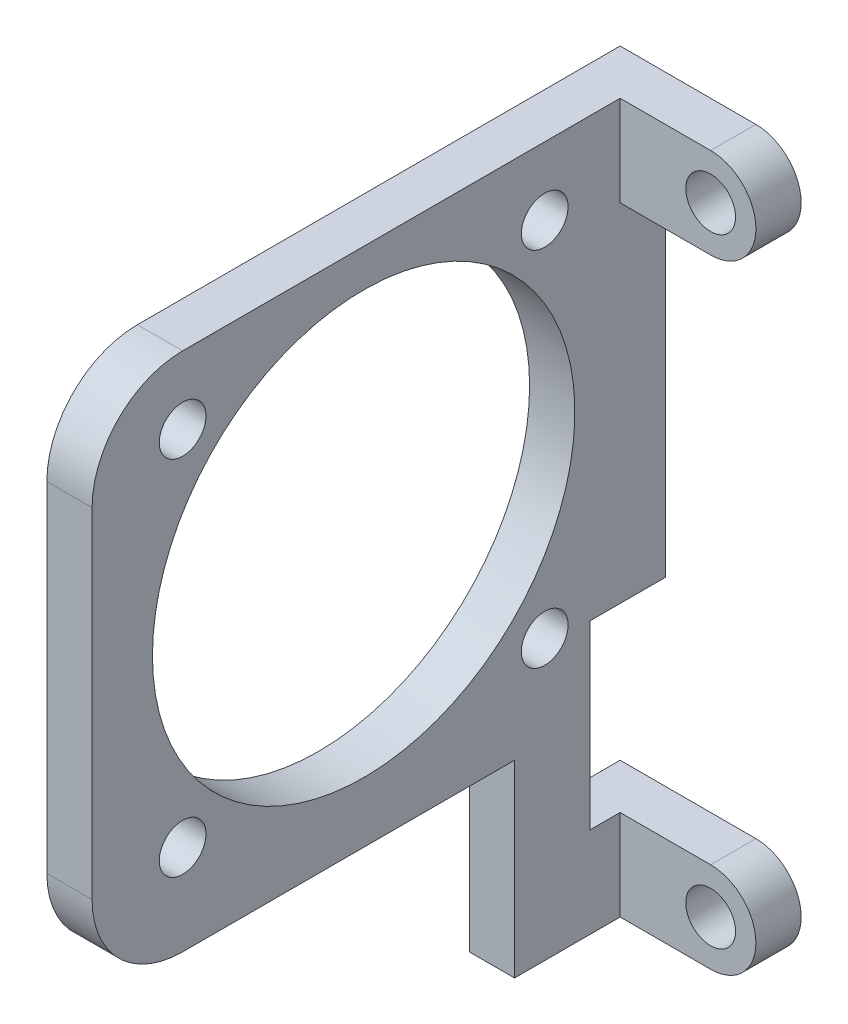
from build123d import *

# Parameters (mm, degrees)
ESBO_O1_R                  = 1.65
RESSALTO_EXTRUS_O1_DEPTH   = 40
ESBO_O2_W                  = 9
ESBO_O2_H                  = 37
CORTE_EXTRUS_O1_DEPTH      = 48
ESBO_O3_R                  = 14
ESBO_O3_R_2                = 1.55
ESBO_O3_W                  = 5
ESBO_O3_H                  = 12
CORTE_EXTRUS_O2_DEPTH      = 1
CORTE_EXTRUS_O2_DEPTH_BACK = 3
FILETE1_R                  = 6


with BuildPart() as part:
    # Esboço1 → Ressalto-extrusão1 (new body)
    with BuildSketch(Plane.XY):
        with BuildLine():
            Line((0, 23.5), (-9, 23.5))
            Line((-9, 23.5), (-9, -23.5))
            Line((-9, -23.5), (0, -23.5))
            ThreePointArc((0, -23.5), (3, -20.5), (0, -17.5))
            Line((0, -17.5), (-6, -17.5))
            Line((-6, -17.5), (-6, 17.5))
            Line((-6, 17.5), (0, 17.5))
            ThreePointArc((0, 17.5), (3, 20.5), (0, 23.5))
        make_face()
        with Locations((0, 20.5)):
            Circle(ESBO_O1_R, mode=Mode.SUBTRACT)
        with Locations((0, -20.5)):
            Circle(ESBO_O1_R, mode=Mode.SUBTRACT)
    extrude(amount=RESSALTO_EXTRUS_O1_DEPTH)

    # Esboço2 → Corte-extrusão1 (cut, through all)
    with BuildSketch(Plane.XZ.offset(23.5)):
        with Locations((-1.5, 21.5)):
            Rectangle(ESBO_O2_W, ESBO_O2_H)
    extrude(amount=-CORTE_EXTRUS_O1_DEPTH, mode=Mode.SUBTRACT)

    # Esboço3 → Corte-extrusão2 (cut, two sides)
    with BuildSketch(Plane.ZY.offset(9)) as corte_extrus_o2_sk:
        with Locations((20, 7)):
            Circle(ESBO_O3_R)
        with Locations((32, 19)):
            Circle(ESBO_O3_R_2)
        with Locations((32, -5)):
            Circle(ESBO_O3_R_2)
        with Locations((8, -5)):
            Circle(ESBO_O3_R_2)
        with Locations((8, 19)):
            Circle(ESBO_O3_R_2)
        with Locations((2.5, -11.5)):
            Rectangle(ESBO_O3_W, ESBO_O3_H)
        Polygon((10, -23.5), (10, -11), (38, -11), (38, 23.5), (40, 23.5), (40, -8), (40, -23.5), align=None)
    extrude(amount=CORTE_EXTRUS_O2_DEPTH, mode=Mode.SUBTRACT)
    extrude(corte_extrus_o2_sk.sketch, amount=-CORTE_EXTRUS_O2_DEPTH_BACK, mode=Mode.SUBTRACT)

    # Filete1
    filete1_edges = [part.edges().sort_by_distance(p)[0] for p in [
        (-7.5, -11, 38),
        (-7.5, 23.5, 38),
    ]]
    fillet(filete1_edges, radius=FILETE1_R)


solid = part.part
